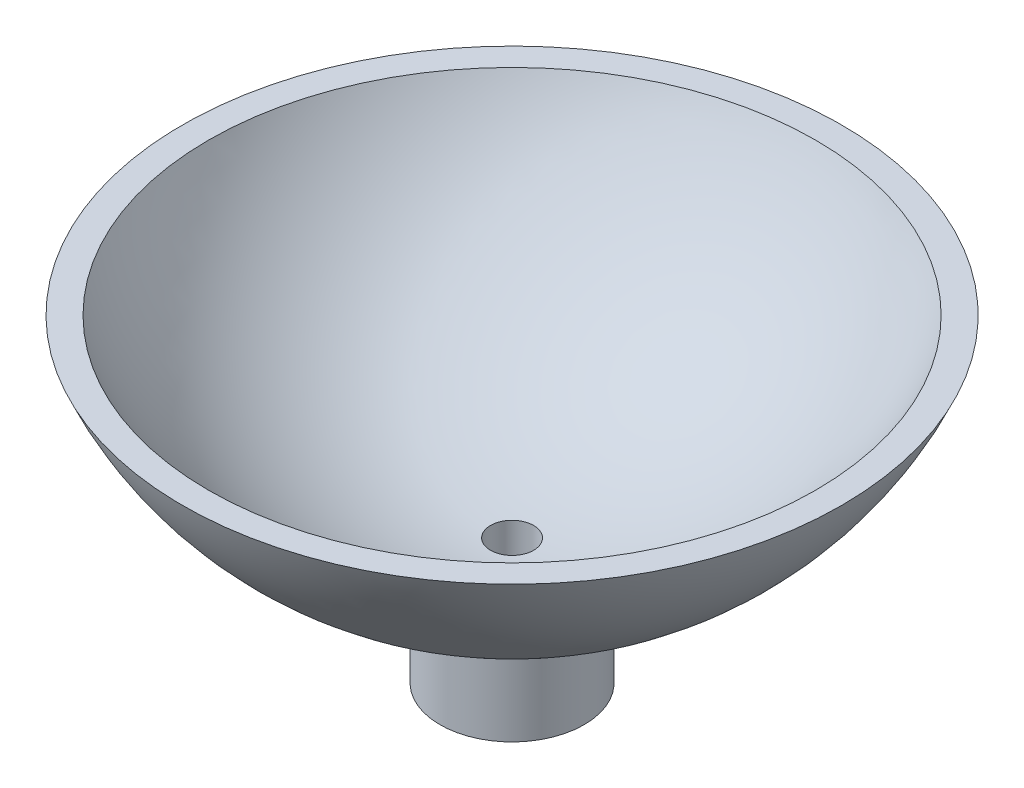
from build123d import *


with BuildPart() as part:
    # Sketch5 → Revolve2 (revolve)
    with BuildSketch(Plane.XY):
        with BuildLine():
            Line((-1.35255, -28.85), (-1.35255, -22.459310063))
            Line((-1.35255, -22.459310063), (-1.35255, -20.956397794))
            ThreePointArc((-1.35255, -20.956397794), (-11.859468122, -17.33069577), (-19.044093573, -8.85))
            Line((-19.044093573, -8.85), (-20.686408581, -8.85))
            ThreePointArc((-20.686408581, -8.85), (-14.227733814, -17.430478781), (-4.52755, -22.039766128))
            Line((-4.52755, -22.039766128), (-4.52755, -28.85))
            Line((-4.52755, -28.85), (-1.35255, -28.85))
        make_face()
    revolve(axis=Axis((0, -28.85, 0), (0, 1, 0)))


solid = part.part
